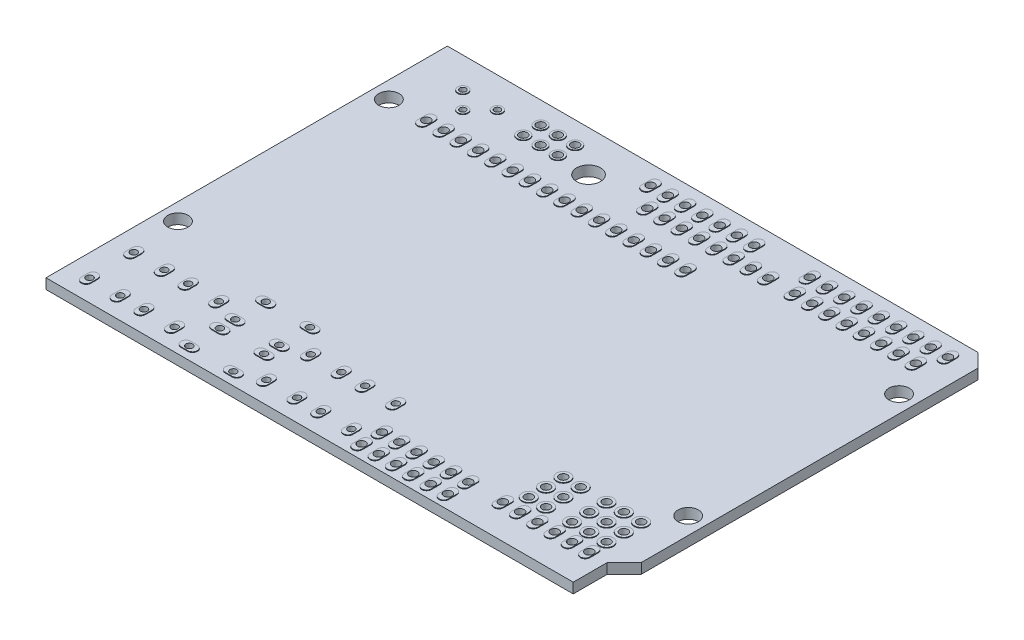
from build123d import *

# Parameters (mm, degrees)
SKETCH1_R                = 0.6
SKETCH1_R_2              = 1.5
SKETCH1_R_3              = 0.5
SKETCH1_R_4              = 0.45
SKETCH1_R_5              = 1.75
PCB_DEPTH                = 1.5
SKETCH2_R                = 0.9
SKETCH2_R_2              = 0.6
SKETCH2_R_3              = 1
SKETCH2_R_4              = 0.75
SKETCH2_R_5              = 0.45
SKETCH2_R_6              = 0.5
BOSS_EXTRUDE1_DEPTH      = 0.1
BOSS_EXTRUDE1_DEPTH_BACK = 1.61


with BuildPart() as part:
    # Sketch1 → PCB (new body)
    with BuildSketch(Plane(origin=(0, 0, 0), x_dir=(1, 0, 0), z_dir=(0, 1, 0))):
        Polygon((0, 0), (77.5, 0), (77.5, 5), (80, 7.5), (80, 57), (78, 59), (0, 59), align=None)
        with Locations((17, 55.7)):
            Circle(SKETCH1_R, mode=Mode.SUBTRACT)
        with Locations((19.54, 55.7)):
            Circle(SKETCH1_R, mode=Mode.SUBTRACT)
        with Locations((22.08, 55.7)):
            Circle(SKETCH1_R, mode=Mode.SUBTRACT)
        with Locations((19.54, 53.16)):
            Circle(SKETCH1_R, mode=Mode.SUBTRACT)
        with Locations((22.08, 53.16)):
            Circle(SKETCH1_R, mode=Mode.SUBTRACT)
        with Locations((17, 53.16)):
            Circle(SKETCH1_R, mode=Mode.SUBTRACT)
        with Locations((32.76224884, 56.1)):
            Circle(SKETCH1_R, mode=Mode.SUBTRACT)
        with Locations((35.433136068, 52.95)):
            Circle(SKETCH1_R, mode=Mode.SUBTRACT)
        with Locations((35.30224884, 56.1)):
            Circle(SKETCH1_R, mode=Mode.SUBTRACT)
        with Locations((37.84224884, 56.1)):
            Circle(SKETCH1_R, mode=Mode.SUBTRACT)
        with Locations((40.38224884, 56.1)):
            Circle(SKETCH1_R, mode=Mode.SUBTRACT)
        with Locations((42.92224884, 56.1)):
            Circle(SKETCH1_R, mode=Mode.SUBTRACT)
        with Locations((45.46224884, 56.1)):
            Circle(SKETCH1_R, mode=Mode.SUBTRACT)
        with Locations((48.00224884, 56.1)):
            Circle(SKETCH1_R, mode=Mode.SUBTRACT)
        with Locations((37.973136068, 52.95)):
            Circle(SKETCH1_R, mode=Mode.SUBTRACT)
        with Locations((40.513136068, 52.95)):
            Circle(SKETCH1_R, mode=Mode.SUBTRACT)
        with Locations((43.053136068, 52.95)):
            Circle(SKETCH1_R, mode=Mode.SUBTRACT)
        with Locations((45.593136068, 52.95)):
            Circle(SKETCH1_R, mode=Mode.SUBTRACT)
        with Locations((48.133136068, 52.95)):
            Circle(SKETCH1_R, mode=Mode.SUBTRACT)
        with Locations((50.673136068, 52.95)):
            Circle(SKETCH1_R, mode=Mode.SUBTRACT)
        with Locations((53.213136068, 52.95)):
            Circle(SKETCH1_R, mode=Mode.SUBTRACT)
        with Locations((56.16224884, 56.1)):
            Circle(SKETCH1_R, mode=Mode.SUBTRACT)
        with Locations((57.130136068, 52.95)):
            Circle(SKETCH1_R, mode=Mode.SUBTRACT)
        with Locations((59.670136068, 52.95)):
            Circle(SKETCH1_R, mode=Mode.SUBTRACT)
        with Locations((62.210136068, 52.95)):
            Circle(SKETCH1_R, mode=Mode.SUBTRACT)
        with Locations((64.750136068, 52.95)):
            Circle(SKETCH1_R, mode=Mode.SUBTRACT)
        with Locations((67.290136068, 52.95)):
            Circle(SKETCH1_R, mode=Mode.SUBTRACT)
        with Locations((69.830136068, 52.95)):
            Circle(SKETCH1_R, mode=Mode.SUBTRACT)
        with Locations((72.370136068, 52.95)):
            Circle(SKETCH1_R, mode=Mode.SUBTRACT)
        with Locations((74.910136068, 52.95)):
            Circle(SKETCH1_R, mode=Mode.SUBTRACT)
        with Locations((58.70224884, 56.1)):
            Circle(SKETCH1_R, mode=Mode.SUBTRACT)
        with Locations((61.24224884, 56.1)):
            Circle(SKETCH1_R, mode=Mode.SUBTRACT)
        with Locations((63.78224884, 56.1)):
            Circle(SKETCH1_R, mode=Mode.SUBTRACT)
        with Locations((66.32224884, 56.1)):
            Circle(SKETCH1_R, mode=Mode.SUBTRACT)
        with Locations((68.86224884, 56.1)):
            Circle(SKETCH1_R, mode=Mode.SUBTRACT)
        with Locations((71.40224884, 56.1)):
            Circle(SKETCH1_R, mode=Mode.SUBTRACT)
        with Locations((73.94224884, 56.1)):
            Circle(SKETCH1_R, mode=Mode.SUBTRACT)
        with Locations((76.48224884, 56.1)):
            Circle(SKETCH1_R, mode=Mode.SUBTRACT)
        with Locations((8, 47.9)):
            Circle(SKETCH1_R, mode=Mode.SUBTRACT)
        with Locations((10.54, 47.9)):
            Circle(SKETCH1_R, mode=Mode.SUBTRACT)
        with Locations((13.08, 47.9)):
            Circle(SKETCH1_R, mode=Mode.SUBTRACT)
        with Locations((15.62, 47.9)):
            Circle(SKETCH1_R, mode=Mode.SUBTRACT)
        with Locations((18.16, 47.9)):
            Circle(SKETCH1_R, mode=Mode.SUBTRACT)
        with Locations((20.7, 47.9)):
            Circle(SKETCH1_R, mode=Mode.SUBTRACT)
        with Locations((23.24, 47.9)):
            Circle(SKETCH1_R, mode=Mode.SUBTRACT)
        with Locations((25.78, 47.9)):
            Circle(SKETCH1_R, mode=Mode.SUBTRACT)
        with Locations((28.32, 47.9)):
            Circle(SKETCH1_R, mode=Mode.SUBTRACT)
        with Locations((30.86, 47.9)):
            Circle(SKETCH1_R, mode=Mode.SUBTRACT)
        with Locations((33.4, 47.9)):
            Circle(SKETCH1_R, mode=Mode.SUBTRACT)
        with Locations((35.94, 47.9)):
            Circle(SKETCH1_R, mode=Mode.SUBTRACT)
        with Locations((38.48, 47.9)):
            Circle(SKETCH1_R, mode=Mode.SUBTRACT)
        with Locations((41.02, 47.9)):
            Circle(SKETCH1_R, mode=Mode.SUBTRACT)
        with Locations((43.56, 47.9)):
            Circle(SKETCH1_R, mode=Mode.SUBTRACT)
        with Locations((46.1, 47.9)):
            Circle(SKETCH1_R, mode=Mode.SUBTRACT)
        with Locations((74.910136068, 4.95)):
            Circle(SKETCH1_R, mode=Mode.SUBTRACT)
        with Locations((72.370136068, 4.95)):
            Circle(SKETCH1_R, mode=Mode.SUBTRACT)
        with Locations((69.830136068, 4.95)):
            Circle(SKETCH1_R, mode=Mode.SUBTRACT)
        with Locations((67.290136068, 4.95)):
            Circle(SKETCH1_R, mode=Mode.SUBTRACT)
        with Locations((64.750136068, 4.95)):
            Circle(SKETCH1_R, mode=Mode.SUBTRACT)
        with Locations((62.210136068, 4.95)):
            Circle(SKETCH1_R, mode=Mode.SUBTRACT)
        with Locations((57.130136068, 4.95)):
            Circle(SKETCH1_R, mode=Mode.SUBTRACT)
        with Locations((54.590136068, 4.95)):
            Circle(SKETCH1_R, mode=Mode.SUBTRACT)
        with Locations((52.050136068, 4.95)):
            Circle(SKETCH1_R, mode=Mode.SUBTRACT)
        with Locations((49.510136068, 4.95)):
            Circle(SKETCH1_R, mode=Mode.SUBTRACT)
        with Locations((46.970136068, 4.95)):
            Circle(SKETCH1_R, mode=Mode.SUBTRACT)
        with Locations((44.430136068, 4.95)):
            Circle(SKETCH1_R, mode=Mode.SUBTRACT)
        with Locations((57.130136068, 1.95)):
            Circle(SKETCH1_R, mode=Mode.SUBTRACT)
        with Locations((54.590136068, 1.95)):
            Circle(SKETCH1_R, mode=Mode.SUBTRACT)
        with Locations((52.050136068, 1.95)):
            Circle(SKETCH1_R, mode=Mode.SUBTRACT)
        with Locations((49.510136068, 1.95)):
            Circle(SKETCH1_R, mode=Mode.SUBTRACT)
        with Locations((46.970136068, 1.95)):
            Circle(SKETCH1_R, mode=Mode.SUBTRACT)
        with Locations((44.430136068, 1.95)):
            Circle(SKETCH1_R, mode=Mode.SUBTRACT)
        with Locations((63.480136068, 7.49)):
            Circle(SKETCH1_R, mode=Mode.SUBTRACT)
        with Locations((74.910136068, 7.49)):
            Circle(SKETCH1_R, mode=Mode.SUBTRACT)
        with Locations((72.370136068, 7.49)):
            Circle(SKETCH1_R, mode=Mode.SUBTRACT)
        with Locations((69.830136068, 7.49)):
            Circle(SKETCH1_R, mode=Mode.SUBTRACT)
        with Locations((74.910136068, 10.03)):
            Circle(SKETCH1_R, mode=Mode.SUBTRACT)
        with Locations((72.370136068, 10.03)):
            Circle(SKETCH1_R, mode=Mode.SUBTRACT)
        with Locations((69.830136068, 10.03)):
            Circle(SKETCH1_R, mode=Mode.SUBTRACT)
        with Locations((74.910136068, 12.57)):
            Circle(SKETCH1_R, mode=Mode.SUBTRACT)
        with Locations((72.370136068, 12.57)):
            Circle(SKETCH1_R, mode=Mode.SUBTRACT)
        with Locations((69.830136068, 12.57)):
            Circle(SKETCH1_R, mode=Mode.SUBTRACT)
        with Locations((66.020136068, 7.49)):
            Circle(SKETCH1_R, mode=Mode.SUBTRACT)
        with Locations((66.020136068, 10.03)):
            Circle(SKETCH1_R, mode=Mode.SUBTRACT)
        with Locations((66.020136068, 12.57)):
            Circle(SKETCH1_R, mode=Mode.SUBTRACT)
        with Locations((63.480136068, 10.03)):
            Circle(SKETCH1_R, mode=Mode.SUBTRACT)
        with Locations((63.480136068, 12.57)):
            Circle(SKETCH1_R, mode=Mode.SUBTRACT)
        with Locations((2.5, 47.9)):
            Circle(SKETCH1_R_2, mode=Mode.SUBTRACT)
        with Locations((77.5, 47.9)):
            Circle(SKETCH1_R_2, mode=Mode.SUBTRACT)
        with Locations((77.5, 16.9)):
            Circle(SKETCH1_R_2, mode=Mode.SUBTRACT)
        with Locations((2.5, 16.9)):
            Circle(SKETCH1_R_2, mode=Mode.SUBTRACT)
        with Locations((3.3, 9.6)):
            Circle(SKETCH1_R_3, mode=Mode.SUBTRACT)
        with Locations((7.8, 9.6)):
            Circle(SKETCH1_R_3, mode=Mode.SUBTRACT)
        with Locations((7.8, 3.1)):
            Circle(SKETCH1_R_3, mode=Mode.SUBTRACT)
        with Locations((3.3, 3.1)):
            Circle(SKETCH1_R_3, mode=Mode.SUBTRACT)
        with Locations((11.3, 9.6)):
            Circle(SKETCH1_R_3, mode=Mode.SUBTRACT)
        with Locations((15.8, 9.6)):
            Circle(SKETCH1_R_3, mode=Mode.SUBTRACT)
        with Locations((15.8, 3.1)):
            Circle(SKETCH1_R_3, mode=Mode.SUBTRACT)
        with Locations((11.3, 3.1)):
            Circle(SKETCH1_R_3, mode=Mode.SUBTRACT)
        with Locations((29.3, 9.6)):
            Circle(SKETCH1_R_3, mode=Mode.SUBTRACT)
        with Locations((33.8, 9.6)):
            Circle(SKETCH1_R_3, mode=Mode.SUBTRACT)
        with Locations((33.8, 3.1)):
            Circle(SKETCH1_R_3, mode=Mode.SUBTRACT)
        with Locations((29.3, 3.1)):
            Circle(SKETCH1_R_3, mode=Mode.SUBTRACT)
        with Locations((41.8, 3.1)):
            Circle(SKETCH1_R_3, mode=Mode.SUBTRACT)
        with Locations((41.8, 9.6)):
            Circle(SKETCH1_R_3, mode=Mode.SUBTRACT)
        with Locations((37.3, 9.6)):
            Circle(SKETCH1_R_3, mode=Mode.SUBTRACT)
        with Locations((37.3, 3.1)):
            Circle(SKETCH1_R_3, mode=Mode.SUBTRACT)
        with Locations((19.3, 6.25)):
            Circle(SKETCH1_R_3, mode=Mode.SUBTRACT)
        with Locations((25.8, 6.25)):
            Circle(SKETCH1_R_3, mode=Mode.SUBTRACT)
        with Locations((25.8, 1.75)):
            Circle(SKETCH1_R_3, mode=Mode.SUBTRACT)
        with Locations((19.3, 1.75)):
            Circle(SKETCH1_R_3, mode=Mode.SUBTRACT)
        with Locations((19.3, 13)):
            Circle(SKETCH1_R_3, mode=Mode.SUBTRACT)
        with Locations((19.3, 8.5)):
            Circle(SKETCH1_R_3, mode=Mode.SUBTRACT)
        with Locations((25.8, 13)):
            Circle(SKETCH1_R_3, mode=Mode.SUBTRACT)
        with Locations((25.8, 8.5)):
            Circle(SKETCH1_R_3, mode=Mode.SUBTRACT)
        with Locations((6.8, 54.47)):
            Circle(SKETCH1_R_4, mode=Mode.SUBTRACT)
        with Locations((11.88, 54.47)):
            Circle(SKETCH1_R_4, mode=Mode.SUBTRACT)
        with Locations((9.34, 51.93)):
            Circle(SKETCH1_R_4, mode=Mode.SUBTRACT)
        with Locations((26.75, 53)):
            Circle(SKETCH1_R_5, mode=Mode.SUBTRACT)
    extrude(amount=-PCB_DEPTH)

    # Sketch2 → Boss-Extrude1 (add, two sides)
    with BuildSketch(Plane(origin=(0, 0, 0), x_dir=(1, 0, 0), z_dir=(0, 1, 0))) as boss_extrude1_sk:
        with Locations((17, 55.7)):
            Circle(SKETCH2_R)
        with Locations((17, 55.7)):
            Circle(SKETCH2_R_2, mode=Mode.SUBTRACT)
        with Locations((17, 53.16)):
            Circle(SKETCH2_R)
        with Locations((17, 53.16)):
            Circle(SKETCH2_R_2, mode=Mode.SUBTRACT)
        with Locations((19.54, 53.16)):
            Circle(SKETCH2_R)
        with Locations((19.54, 53.16)):
            Circle(SKETCH2_R_2, mode=Mode.SUBTRACT)
        with Locations((19.54, 55.7)):
            Circle(SKETCH2_R)
        with Locations((19.54, 55.7)):
            Circle(SKETCH2_R_2, mode=Mode.SUBTRACT)
        with Locations((22.08, 55.7)):
            Circle(SKETCH2_R)
        with Locations((22.08, 55.7)):
            Circle(SKETCH2_R_2, mode=Mode.SUBTRACT)
        with Locations((22.08, 53.16)):
            Circle(SKETCH2_R)
        with Locations((22.08, 53.16)):
            Circle(SKETCH2_R_2, mode=Mode.SUBTRACT)
        with Locations((63.480136068, 7.49)):
            Circle(SKETCH2_R_3)
        with Locations((63.480136068, 7.49)):
            Circle(SKETCH2_R_2, mode=Mode.SUBTRACT)
        with Locations((69.830136068, 7.49)):
            Circle(SKETCH2_R_3)
        with Locations((69.830136068, 7.49)):
            Circle(SKETCH2_R_2, mode=Mode.SUBTRACT)
        with Locations((63.480136068, 12.57)):
            Circle(SKETCH2_R_3)
        with Locations((63.480136068, 12.57)):
            Circle(SKETCH2_R_2, mode=Mode.SUBTRACT)
        with Locations((63.480136068, 10.03)):
            Circle(SKETCH2_R_3)
        with Locations((63.480136068, 10.03)):
            Circle(SKETCH2_R_2, mode=Mode.SUBTRACT)
        with Locations((66.020136068, 7.49)):
            Circle(SKETCH2_R_3)
        with Locations((66.020136068, 7.49)):
            Circle(SKETCH2_R_2, mode=Mode.SUBTRACT)
        with Locations((66.020136068, 10.03)):
            Circle(SKETCH2_R_3)
        with Locations((66.020136068, 10.03)):
            Circle(SKETCH2_R_2, mode=Mode.SUBTRACT)
        with Locations((66.020136068, 12.57)):
            Circle(SKETCH2_R_3)
        with Locations((66.020136068, 12.57)):
            Circle(SKETCH2_R_2, mode=Mode.SUBTRACT)
        with Locations((69.830136068, 12.57)):
            Circle(SKETCH2_R_3)
        with Locations((69.830136068, 12.57)):
            Circle(SKETCH2_R_2, mode=Mode.SUBTRACT)
        with Locations((69.830136068, 10.03)):
            Circle(SKETCH2_R_3)
        with Locations((69.830136068, 10.03)):
            Circle(SKETCH2_R_2, mode=Mode.SUBTRACT)
        with Locations((72.370136068, 10.03)):
            Circle(SKETCH2_R_3)
        with Locations((72.370136068, 10.03)):
            Circle(SKETCH2_R_2, mode=Mode.SUBTRACT)
        with Locations((72.370136068, 12.57)):
            Circle(SKETCH2_R_3)
        with Locations((72.370136068, 12.57)):
            Circle(SKETCH2_R_2, mode=Mode.SUBTRACT)
        with Locations((74.910136068, 12.57)):
            Circle(SKETCH2_R_3)
        with Locations((74.910136068, 12.57)):
            Circle(SKETCH2_R_2, mode=Mode.SUBTRACT)
        with Locations((74.910136068, 10.03)):
            Circle(SKETCH2_R_3)
        with Locations((74.910136068, 10.03)):
            Circle(SKETCH2_R_2, mode=Mode.SUBTRACT)
        with Locations((74.910136068, 7.49)):
            Circle(SKETCH2_R_3)
        with Locations((74.910136068, 7.49)):
            Circle(SKETCH2_R_2, mode=Mode.SUBTRACT)
        with Locations((72.370136068, 7.49)):
            Circle(SKETCH2_R_3)
        with Locations((72.370136068, 7.49)):
            Circle(SKETCH2_R_2, mode=Mode.SUBTRACT)
        with Locations((6.8, 54.47)):
            Circle(SKETCH2_R_4)
        with Locations((6.8, 54.47)):
            Circle(SKETCH2_R_5, mode=Mode.SUBTRACT)
        with Locations((9.34, 51.93)):
            Circle(SKETCH2_R_4)
        with Locations((9.34, 51.93)):
            Circle(SKETCH2_R_5, mode=Mode.SUBTRACT)
        with Locations((11.88, 54.47)):
            Circle(SKETCH2_R_4)
        with Locations((11.88, 54.47)):
            Circle(SKETCH2_R_5, mode=Mode.SUBTRACT)
        with BuildLine():
            Line((33.46224884, 56.7), (33.46224884, 55.5))
            ThreePointArc((33.46224884, 55.5), (32.76224884, 54.8), (32.06224884, 55.5))
            Line((32.06224884, 55.5), (32.06224884, 56.7))
            ThreePointArc((32.06224884, 56.7), (32.76224884, 57.4), (33.46224884, 56.7))
        make_face()
        with Locations((32.76224884, 56.1)):
            Circle(SKETCH2_R_2, mode=Mode.SUBTRACT)
        with BuildLine():
            Line((36.00224884, 56.7), (36.00224884, 55.5))
            ThreePointArc((36.00224884, 55.5), (35.30224884, 54.8), (34.60224884, 55.5))
            Line((34.60224884, 55.5), (34.60224884, 56.7))
            ThreePointArc((34.60224884, 56.7), (35.30224884, 57.4), (36.00224884, 56.7))
        make_face()
        with Locations((35.30224884, 56.1)):
            Circle(SKETCH2_R_2, mode=Mode.SUBTRACT)
        with BuildLine():
            Line((38.54224884, 56.7), (38.54224884, 55.5))
            ThreePointArc((38.54224884, 55.5), (37.84224884, 54.8), (37.14224884, 55.5))
            Line((37.14224884, 55.5), (37.14224884, 56.7))
            ThreePointArc((37.14224884, 56.7), (37.84224884, 57.4), (38.54224884, 56.7))
        make_face()
        with Locations((37.84224884, 56.1)):
            Circle(SKETCH2_R_2, mode=Mode.SUBTRACT)
        with BuildLine():
            Line((41.08224884, 56.7), (41.08224884, 55.5))
            ThreePointArc((41.08224884, 55.5), (40.38224884, 54.8), (39.68224884, 55.5))
            Line((39.68224884, 55.5), (39.68224884, 56.7))
            ThreePointArc((39.68224884, 56.7), (40.38224884, 57.4), (41.08224884, 56.7))
        make_face()
        with Locations((40.38224884, 56.1)):
            Circle(SKETCH2_R_2, mode=Mode.SUBTRACT)
        with BuildLine():
            Line((43.62224884, 56.7), (43.62224884, 55.5))
            ThreePointArc((43.62224884, 55.5), (42.92224884, 54.8), (42.22224884, 55.5))
            Line((42.22224884, 55.5), (42.22224884, 56.7))
            ThreePointArc((42.22224884, 56.7), (42.92224884, 57.4), (43.62224884, 56.7))
        make_face()
        with Locations((42.92224884, 56.1)):
            Circle(SKETCH2_R_2, mode=Mode.SUBTRACT)
        with BuildLine():
            Line((46.16224884, 56.7), (46.16224884, 55.5))
            ThreePointArc((46.16224884, 55.5), (45.46224884, 54.8), (44.76224884, 55.5))
            Line((44.76224884, 55.5), (44.76224884, 56.7))
            ThreePointArc((44.76224884, 56.7), (45.46224884, 57.4), (46.16224884, 56.7))
        make_face()
        with Locations((45.46224884, 56.1)):
            Circle(SKETCH2_R_2, mode=Mode.SUBTRACT)
        with BuildLine():
            Line((48.70224884, 56.7), (48.70224884, 55.5))
            ThreePointArc((48.70224884, 55.5), (48.00224884, 54.8), (47.30224884, 55.5))
            Line((47.30224884, 55.5), (47.30224884, 56.7))
            ThreePointArc((47.30224884, 56.7), (48.00224884, 57.4), (48.70224884, 56.7))
        make_face()
        with Locations((48.00224884, 56.1)):
            Circle(SKETCH2_R_2, mode=Mode.SUBTRACT)
        with BuildLine():
            Line((36.133136068, 53.55), (36.133136068, 52.35))
            ThreePointArc((36.133136068, 52.35), (35.433136068, 51.65), (34.733136068, 52.35))
            Line((34.733136068, 52.35), (34.733136068, 53.55))
            ThreePointArc((34.733136068, 53.55), (35.433136068, 54.25), (36.133136068, 53.55))
        make_face()
        with Locations((35.433136068, 52.95)):
            Circle(SKETCH2_R_2, mode=Mode.SUBTRACT)
        with BuildLine():
            Line((56.86224884, 56.7), (56.86224884, 55.5))
            ThreePointArc((56.86224884, 55.5), (56.16224884, 54.8), (55.46224884, 55.5))
            Line((55.46224884, 55.5), (55.46224884, 56.7))
            ThreePointArc((55.46224884, 56.7), (56.16224884, 57.4), (56.86224884, 56.7))
        make_face()
        with Locations((56.16224884, 56.1)):
            Circle(SKETCH2_R_2, mode=Mode.SUBTRACT)
        with BuildLine():
            Line((57.830136068, 53.55), (57.830136068, 52.35))
            ThreePointArc((57.830136068, 52.35), (57.130136068, 51.65), (56.430136068, 52.35))
            Line((56.430136068, 52.35), (56.430136068, 53.55))
            ThreePointArc((56.430136068, 53.55), (57.130136068, 54.25), (57.830136068, 53.55))
        make_face()
        with Locations((57.130136068, 52.95)):
            Circle(SKETCH2_R_2, mode=Mode.SUBTRACT)
        with BuildLine():
            Line((8.7, 48.5), (8.7, 47.3))
            ThreePointArc((8.7, 47.3), (8, 46.6), (7.3, 47.3))
            Line((7.3, 47.3), (7.3, 48.5))
            ThreePointArc((7.3, 48.5), (8, 49.2), (8.7, 48.5))
        make_face()
        with Locations((8, 47.9)):
            Circle(SKETCH2_R_2, mode=Mode.SUBTRACT)
        with BuildLine():
            Line((4, 10.1), (4, 9.1))
            ThreePointArc((4, 9.1), (3.3, 8.4), (2.6, 9.1))
            Line((2.6, 9.1), (2.6, 10.1))
            ThreePointArc((2.6, 10.1), (3.3, 10.8), (4, 10.1))
        make_face()
        with Locations((3.3, 9.6)):
            Circle(SKETCH2_R_6, mode=Mode.SUBTRACT)
        with BuildLine():
            Line((18.8, 2.45), (19.8, 2.45))
            ThreePointArc((19.8, 2.45), (20.5, 1.75), (19.8, 1.05))
            Line((19.8, 1.05), (18.8, 1.05))
            ThreePointArc((18.8, 1.05), (18.1, 1.75), (18.8, 2.45))
        make_face()
        with Locations((19.3, 1.75)):
            Circle(SKETCH2_R_6, mode=Mode.SUBTRACT)
        with BuildLine():
            Line((30, 10.1), (30, 9.1))
            ThreePointArc((30, 9.1), (29.3, 8.4), (28.6, 9.1))
            Line((28.6, 9.1), (28.6, 10.1))
            ThreePointArc((28.6, 10.1), (29.3, 10.8), (30, 10.1))
        make_face()
        with Locations((29.3, 9.6)):
            Circle(SKETCH2_R_6, mode=Mode.SUBTRACT)
        with BuildLine():
            Line((45.130136068, 5.55), (45.130136068, 4.35))
            ThreePointArc((45.130136068, 4.35), (44.430136068, 3.65), (43.730136068, 4.35))
            Line((43.730136068, 4.35), (43.730136068, 5.55))
            ThreePointArc((43.730136068, 5.55), (44.430136068, 6.25), (45.130136068, 5.55))
        make_face()
        with Locations((44.430136068, 4.95)):
            Circle(SKETCH2_R_2, mode=Mode.SUBTRACT)
        with BuildLine():
            Line((61.510136068, 4.35), (61.510136068, 5.55))
            ThreePointArc((61.510136068, 5.55), (62.210136068, 6.25), (62.910136068, 5.55))
            Line((62.910136068, 5.55), (62.910136068, 4.35))
            ThreePointArc((62.910136068, 4.35), (62.210136068, 3.65), (61.510136068, 4.35))
        make_face()
        with Locations((62.210136068, 4.95)):
            Circle(SKETCH2_R_2, mode=Mode.SUBTRACT)
        with BuildLine():
            Line((8.5, 10.1), (8.5, 9.1))
            ThreePointArc((8.5, 9.1), (7.8, 8.4), (7.1, 9.1))
            Line((7.1, 9.1), (7.1, 10.1))
            ThreePointArc((7.1, 10.1), (7.8, 10.8), (8.5, 10.1))
        make_face()
        with Locations((7.8, 9.6)):
            Circle(SKETCH2_R_6, mode=Mode.SUBTRACT)
        with BuildLine():
            Line((8.5, 3.6), (8.5, 2.6))
            ThreePointArc((8.5, 2.6), (7.8, 1.9), (7.1, 2.6))
            Line((7.1, 2.6), (7.1, 3.6))
            ThreePointArc((7.1, 3.6), (7.8, 4.3), (8.5, 3.6))
        make_face()
        with Locations((7.8, 3.1)):
            Circle(SKETCH2_R_6, mode=Mode.SUBTRACT)
        with BuildLine():
            Line((38.673136068, 53.55), (38.673136068, 52.35))
            ThreePointArc((38.673136068, 52.35), (37.973136068, 51.65), (37.273136068, 52.35))
            Line((37.273136068, 52.35), (37.273136068, 53.55))
            ThreePointArc((37.273136068, 53.55), (37.973136068, 54.25), (38.673136068, 53.55))
        make_face()
        with Locations((37.973136068, 52.95)):
            Circle(SKETCH2_R_2, mode=Mode.SUBTRACT)
        with BuildLine():
            Line((60.370136068, 53.55), (60.370136068, 52.35))
            ThreePointArc((60.370136068, 52.35), (59.670136068, 51.65), (58.970136068, 52.35))
            Line((58.970136068, 52.35), (58.970136068, 53.55))
            ThreePointArc((58.970136068, 53.55), (59.670136068, 54.25), (60.370136068, 53.55))
        make_face()
        with Locations((59.670136068, 52.95)):
            Circle(SKETCH2_R_2, mode=Mode.SUBTRACT)
        with BuildLine():
            Line((41.213136068, 53.55), (41.213136068, 52.35))
            ThreePointArc((41.213136068, 52.35), (40.513136068, 51.65), (39.813136068, 52.35))
            Line((39.813136068, 52.35), (39.813136068, 53.55))
            ThreePointArc((39.813136068, 53.55), (40.513136068, 54.25), (41.213136068, 53.55))
        make_face()
        with Locations((40.513136068, 52.95)):
            Circle(SKETCH2_R_2, mode=Mode.SUBTRACT)
        with BuildLine():
            Line((62.910136068, 53.55), (62.910136068, 52.35))
            ThreePointArc((62.910136068, 52.35), (62.210136068, 51.65), (61.510136068, 52.35))
            Line((61.510136068, 52.35), (61.510136068, 53.55))
            ThreePointArc((61.510136068, 53.55), (62.210136068, 54.25), (62.910136068, 53.55))
        make_face()
        with Locations((62.210136068, 52.95)):
            Circle(SKETCH2_R_2, mode=Mode.SUBTRACT)
        with BuildLine():
            Line((43.753136068, 53.55), (43.753136068, 52.35))
            ThreePointArc((43.753136068, 52.35), (43.053136068, 51.65), (42.353136068, 52.35))
            Line((42.353136068, 52.35), (42.353136068, 53.55))
            ThreePointArc((42.353136068, 53.55), (43.053136068, 54.25), (43.753136068, 53.55))
        make_face()
        with Locations((43.053136068, 52.95)):
            Circle(SKETCH2_R_2, mode=Mode.SUBTRACT)
        with BuildLine():
            Line((65.450136068, 53.55), (65.450136068, 52.35))
            ThreePointArc((65.450136068, 52.35), (64.750136068, 51.65), (64.050136068, 52.35))
            Line((64.050136068, 52.35), (64.050136068, 53.55))
            ThreePointArc((64.050136068, 53.55), (64.750136068, 54.25), (65.450136068, 53.55))
        make_face()
        with Locations((64.750136068, 52.95)):
            Circle(SKETCH2_R_2, mode=Mode.SUBTRACT)
        with BuildLine():
            Line((46.293136068, 53.55), (46.293136068, 52.35))
            ThreePointArc((46.293136068, 52.35), (45.593136068, 51.65), (44.893136068, 52.35))
            Line((44.893136068, 52.35), (44.893136068, 53.55))
            ThreePointArc((44.893136068, 53.55), (45.593136068, 54.25), (46.293136068, 53.55))
        make_face()
        with Locations((45.593136068, 52.95)):
            Circle(SKETCH2_R_2, mode=Mode.SUBTRACT)
        with BuildLine():
            Line((67.990136068, 53.55), (67.990136068, 52.35))
            ThreePointArc((67.990136068, 52.35), (67.290136068, 51.65), (66.590136068, 52.35))
            Line((66.590136068, 52.35), (66.590136068, 53.55))
            ThreePointArc((66.590136068, 53.55), (67.290136068, 54.25), (67.990136068, 53.55))
        make_face()
        with Locations((67.290136068, 52.95)):
            Circle(SKETCH2_R_2, mode=Mode.SUBTRACT)
        with BuildLine():
            Line((48.833136068, 53.55), (48.833136068, 52.35))
            ThreePointArc((48.833136068, 52.35), (48.133136068, 51.65), (47.433136068, 52.35))
            Line((47.433136068, 52.35), (47.433136068, 53.55))
            ThreePointArc((47.433136068, 53.55), (48.133136068, 54.25), (48.833136068, 53.55))
        make_face()
        with Locations((48.133136068, 52.95)):
            Circle(SKETCH2_R_2, mode=Mode.SUBTRACT)
        with BuildLine():
            Line((70.530136068, 53.55), (70.530136068, 52.35))
            ThreePointArc((70.530136068, 52.35), (69.830136068, 51.65), (69.130136068, 52.35))
            Line((69.130136068, 52.35), (69.130136068, 53.55))
            ThreePointArc((69.130136068, 53.55), (69.830136068, 54.25), (70.530136068, 53.55))
        make_face()
        with Locations((69.830136068, 52.95)):
            Circle(SKETCH2_R_2, mode=Mode.SUBTRACT)
        with BuildLine():
            Line((51.373136068, 53.55), (51.373136068, 52.35))
            ThreePointArc((51.373136068, 52.35), (50.673136068, 51.65), (49.973136068, 52.35))
            Line((49.973136068, 52.35), (49.973136068, 53.55))
            ThreePointArc((49.973136068, 53.55), (50.673136068, 54.25), (51.373136068, 53.55))
        make_face()
        with Locations((50.673136068, 52.95)):
            Circle(SKETCH2_R_2, mode=Mode.SUBTRACT)
        with BuildLine():
            Line((73.070136068, 53.55), (73.070136068, 52.35))
            ThreePointArc((73.070136068, 52.35), (72.370136068, 51.65), (71.670136068, 52.35))
            Line((71.670136068, 52.35), (71.670136068, 53.55))
            ThreePointArc((71.670136068, 53.55), (72.370136068, 54.25), (73.070136068, 53.55))
        make_face()
        with Locations((72.370136068, 52.95)):
            Circle(SKETCH2_R_2, mode=Mode.SUBTRACT)
        with BuildLine():
            Line((53.913136068, 53.55), (53.913136068, 52.35))
            ThreePointArc((53.913136068, 52.35), (53.213136068, 51.65), (52.513136068, 52.35))
            Line((52.513136068, 52.35), (52.513136068, 53.55))
            ThreePointArc((52.513136068, 53.55), (53.213136068, 54.25), (53.913136068, 53.55))
        make_face()
        with Locations((53.213136068, 52.95)):
            Circle(SKETCH2_R_2, mode=Mode.SUBTRACT)
        with BuildLine():
            Line((75.610136068, 53.55), (75.610136068, 52.35))
            ThreePointArc((75.610136068, 52.35), (74.910136068, 51.65), (74.210136068, 52.35))
            Line((74.210136068, 52.35), (74.210136068, 53.55))
            ThreePointArc((74.210136068, 53.55), (74.910136068, 54.25), (75.610136068, 53.55))
        make_face()
        with Locations((74.910136068, 52.95)):
            Circle(SKETCH2_R_2, mode=Mode.SUBTRACT)
        with BuildLine():
            Line((59.40224884, 56.7), (59.40224884, 55.5))
            ThreePointArc((59.40224884, 55.5), (58.70224884, 54.8), (58.00224884, 55.5))
            Line((58.00224884, 55.5), (58.00224884, 56.7))
            ThreePointArc((58.00224884, 56.7), (58.70224884, 57.4), (59.40224884, 56.7))
        make_face()
        with Locations((58.70224884, 56.1)):
            Circle(SKETCH2_R_2, mode=Mode.SUBTRACT)
        with BuildLine():
            Line((61.94224884, 56.7), (61.94224884, 55.5))
            ThreePointArc((61.94224884, 55.5), (61.24224884, 54.8), (60.54224884, 55.5))
            Line((60.54224884, 55.5), (60.54224884, 56.7))
            ThreePointArc((60.54224884, 56.7), (61.24224884, 57.4), (61.94224884, 56.7))
        make_face()
        with Locations((61.24224884, 56.1)):
            Circle(SKETCH2_R_2, mode=Mode.SUBTRACT)
        with BuildLine():
            Line((64.48224884, 56.7), (64.48224884, 55.5))
            ThreePointArc((64.48224884, 55.5), (63.78224884, 54.8), (63.08224884, 55.5))
            Line((63.08224884, 55.5), (63.08224884, 56.7))
            ThreePointArc((63.08224884, 56.7), (63.78224884, 57.4), (64.48224884, 56.7))
        make_face()
        with Locations((63.78224884, 56.1)):
            Circle(SKETCH2_R_2, mode=Mode.SUBTRACT)
        with BuildLine():
            Line((67.02224884, 56.7), (67.02224884, 55.5))
            ThreePointArc((67.02224884, 55.5), (66.32224884, 54.8), (65.62224884, 55.5))
            Line((65.62224884, 55.5), (65.62224884, 56.7))
            ThreePointArc((65.62224884, 56.7), (66.32224884, 57.4), (67.02224884, 56.7))
        make_face()
        with Locations((66.32224884, 56.1)):
            Circle(SKETCH2_R_2, mode=Mode.SUBTRACT)
        with BuildLine():
            Line((69.56224884, 56.7), (69.56224884, 55.5))
            ThreePointArc((69.56224884, 55.5), (68.86224884, 54.8), (68.16224884, 55.5))
            Line((68.16224884, 55.5), (68.16224884, 56.7))
            ThreePointArc((68.16224884, 56.7), (68.86224884, 57.4), (69.56224884, 56.7))
        make_face()
        with Locations((68.86224884, 56.1)):
            Circle(SKETCH2_R_2, mode=Mode.SUBTRACT)
        with BuildLine():
            Line((72.10224884, 56.7), (72.10224884, 55.5))
            ThreePointArc((72.10224884, 55.5), (71.40224884, 54.8), (70.70224884, 55.5))
            Line((70.70224884, 55.5), (70.70224884, 56.7))
            ThreePointArc((70.70224884, 56.7), (71.40224884, 57.4), (72.10224884, 56.7))
        make_face()
        with Locations((71.40224884, 56.1)):
            Circle(SKETCH2_R_2, mode=Mode.SUBTRACT)
        with BuildLine():
            Line((74.64224884, 56.7), (74.64224884, 55.5))
            ThreePointArc((74.64224884, 55.5), (73.94224884, 54.8), (73.24224884, 55.5))
            Line((73.24224884, 55.5), (73.24224884, 56.7))
            ThreePointArc((73.24224884, 56.7), (73.94224884, 57.4), (74.64224884, 56.7))
        make_face()
        with Locations((73.94224884, 56.1)):
            Circle(SKETCH2_R_2, mode=Mode.SUBTRACT)
        with BuildLine():
            Line((77.18224884, 56.7), (77.18224884, 55.5))
            ThreePointArc((77.18224884, 55.5), (76.48224884, 54.8), (75.78224884, 55.5))
            Line((75.78224884, 55.5), (75.78224884, 56.7))
            ThreePointArc((75.78224884, 56.7), (76.48224884, 57.4), (77.18224884, 56.7))
        make_face()
        with Locations((76.48224884, 56.1)):
            Circle(SKETCH2_R_2, mode=Mode.SUBTRACT)
        with BuildLine():
            Line((11.24, 48.5), (11.24, 47.3))
            ThreePointArc((11.24, 47.3), (10.54, 46.6), (9.84, 47.3))
            Line((9.84, 47.3), (9.84, 48.5))
            ThreePointArc((9.84, 48.5), (10.54, 49.2), (11.24, 48.5))
        make_face()
        with Locations((10.54, 47.9)):
            Circle(SKETCH2_R_2, mode=Mode.SUBTRACT)
        with BuildLine():
            Line((13.78, 48.5), (13.78, 47.3))
            ThreePointArc((13.78, 47.3), (13.08, 46.6), (12.38, 47.3))
            Line((12.38, 47.3), (12.38, 48.5))
            ThreePointArc((12.38, 48.5), (13.08, 49.2), (13.78, 48.5))
        make_face()
        with Locations((13.08, 47.9)):
            Circle(SKETCH2_R_2, mode=Mode.SUBTRACT)
        with BuildLine():
            Line((16.32, 48.5), (16.32, 47.3))
            ThreePointArc((16.32, 47.3), (15.62, 46.6), (14.92, 47.3))
            Line((14.92, 47.3), (14.92, 48.5))
            ThreePointArc((14.92, 48.5), (15.62, 49.2), (16.32, 48.5))
        make_face()
        with Locations((15.62, 47.9)):
            Circle(SKETCH2_R_2, mode=Mode.SUBTRACT)
        with BuildLine():
            Line((18.86, 48.5), (18.86, 47.3))
            ThreePointArc((18.86, 47.3), (18.16, 46.6), (17.46, 47.3))
            Line((17.46, 47.3), (17.46, 48.5))
            ThreePointArc((17.46, 48.5), (18.16, 49.2), (18.86, 48.5))
        make_face()
        with Locations((18.16, 47.9)):
            Circle(SKETCH2_R_2, mode=Mode.SUBTRACT)
        with BuildLine():
            Line((21.4, 48.5), (21.4, 47.3))
            ThreePointArc((21.4, 47.3), (20.7, 46.6), (20, 47.3))
            Line((20, 47.3), (20, 48.5))
            ThreePointArc((20, 48.5), (20.7, 49.2), (21.4, 48.5))
        make_face()
        with Locations((20.7, 47.9)):
            Circle(SKETCH2_R_2, mode=Mode.SUBTRACT)
        with BuildLine():
            Line((23.94, 48.5), (23.94, 47.3))
            ThreePointArc((23.94, 47.3), (23.24, 46.6), (22.54, 47.3))
            Line((22.54, 47.3), (22.54, 48.5))
            ThreePointArc((22.54, 48.5), (23.24, 49.2), (23.94, 48.5))
        make_face()
        with Locations((23.24, 47.9)):
            Circle(SKETCH2_R_2, mode=Mode.SUBTRACT)
        with BuildLine():
            Line((26.48, 48.5), (26.48, 47.3))
            ThreePointArc((26.48, 47.3), (25.78, 46.6), (25.08, 47.3))
            Line((25.08, 47.3), (25.08, 48.5))
            ThreePointArc((25.08, 48.5), (25.78, 49.2), (26.48, 48.5))
        make_face()
        with Locations((25.78, 47.9)):
            Circle(SKETCH2_R_2, mode=Mode.SUBTRACT)
        with BuildLine():
            Line((29.02, 48.5), (29.02, 47.3))
            ThreePointArc((29.02, 47.3), (28.32, 46.6), (27.62, 47.3))
            Line((27.62, 47.3), (27.62, 48.5))
            ThreePointArc((27.62, 48.5), (28.32, 49.2), (29.02, 48.5))
        make_face()
        with Locations((28.32, 47.9)):
            Circle(SKETCH2_R_2, mode=Mode.SUBTRACT)
        with BuildLine():
            Line((31.56, 48.5), (31.56, 47.3))
            ThreePointArc((31.56, 47.3), (30.86, 46.6), (30.16, 47.3))
            Line((30.16, 47.3), (30.16, 48.5))
            ThreePointArc((30.16, 48.5), (30.86, 49.2), (31.56, 48.5))
        make_face()
        with Locations((30.86, 47.9)):
            Circle(SKETCH2_R_2, mode=Mode.SUBTRACT)
        with BuildLine():
            Line((34.1, 48.5), (34.1, 47.3))
            ThreePointArc((34.1, 47.3), (33.4, 46.6), (32.7, 47.3))
            Line((32.7, 47.3), (32.7, 48.5))
            ThreePointArc((32.7, 48.5), (33.4, 49.2), (34.1, 48.5))
        make_face()
        with Locations((33.4, 47.9)):
            Circle(SKETCH2_R_2, mode=Mode.SUBTRACT)
        with BuildLine():
            Line((36.64, 48.5), (36.64, 47.3))
            ThreePointArc((36.64, 47.3), (35.94, 46.6), (35.24, 47.3))
            Line((35.24, 47.3), (35.24, 48.5))
            ThreePointArc((35.24, 48.5), (35.94, 49.2), (36.64, 48.5))
        make_face()
        with Locations((35.94, 47.9)):
            Circle(SKETCH2_R_2, mode=Mode.SUBTRACT)
        with BuildLine():
            Line((39.18, 48.5), (39.18, 47.3))
            ThreePointArc((39.18, 47.3), (38.48, 46.6), (37.78, 47.3))
            Line((37.78, 47.3), (37.78, 48.5))
            ThreePointArc((37.78, 48.5), (38.48, 49.2), (39.18, 48.5))
        make_face()
        with Locations((38.48, 47.9)):
            Circle(SKETCH2_R_2, mode=Mode.SUBTRACT)
        with BuildLine():
            Line((41.72, 48.5), (41.72, 47.3))
            ThreePointArc((41.72, 47.3), (41.02, 46.6), (40.32, 47.3))
            Line((40.32, 47.3), (40.32, 48.5))
            ThreePointArc((40.32, 48.5), (41.02, 49.2), (41.72, 48.5))
        make_face()
        with Locations((41.02, 47.9)):
            Circle(SKETCH2_R_2, mode=Mode.SUBTRACT)
        with BuildLine():
            Line((44.26, 48.5), (44.26, 47.3))
            ThreePointArc((44.26, 47.3), (43.56, 46.6), (42.86, 47.3))
            Line((42.86, 47.3), (42.86, 48.5))
            ThreePointArc((42.86, 48.5), (43.56, 49.2), (44.26, 48.5))
        make_face()
        with Locations((43.56, 47.9)):
            Circle(SKETCH2_R_2, mode=Mode.SUBTRACT)
        with BuildLine():
            Line((46.8, 48.5), (46.8, 47.3))
            ThreePointArc((46.8, 47.3), (46.1, 46.6), (45.4, 47.3))
            Line((45.4, 47.3), (45.4, 48.5))
            ThreePointArc((45.4, 48.5), (46.1, 49.2), (46.8, 48.5))
        make_face()
        with Locations((46.1, 47.9)):
            Circle(SKETCH2_R_2, mode=Mode.SUBTRACT)
        with BuildLine():
            Line((47.670136068, 5.55), (47.670136068, 4.35))
            ThreePointArc((47.670136068, 4.35), (46.970136068, 3.65), (46.270136068, 4.35))
            Line((46.270136068, 4.35), (46.270136068, 5.55))
            ThreePointArc((46.270136068, 5.55), (46.970136068, 6.25), (47.670136068, 5.55))
        make_face()
        with Locations((46.970136068, 4.95)):
            Circle(SKETCH2_R_2, mode=Mode.SUBTRACT)
        with BuildLine():
            Line((50.210136068, 5.55), (50.210136068, 4.35))
            ThreePointArc((50.210136068, 4.35), (49.510136068, 3.65), (48.810136068, 4.35))
            Line((48.810136068, 4.35), (48.810136068, 5.55))
            ThreePointArc((48.810136068, 5.55), (49.510136068, 6.25), (50.210136068, 5.55))
        make_face()
        with Locations((49.510136068, 4.95)):
            Circle(SKETCH2_R_2, mode=Mode.SUBTRACT)
        with BuildLine():
            Line((52.750136068, 5.55), (52.750136068, 4.35))
            ThreePointArc((52.750136068, 4.35), (52.050136068, 3.65), (51.350136068, 4.35))
            Line((51.350136068, 4.35), (51.350136068, 5.55))
            ThreePointArc((51.350136068, 5.55), (52.050136068, 6.25), (52.750136068, 5.55))
        make_face()
        with Locations((52.050136068, 4.95)):
            Circle(SKETCH2_R_2, mode=Mode.SUBTRACT)
        with BuildLine():
            Line((55.290136068, 5.55), (55.290136068, 4.35))
            ThreePointArc((55.290136068, 4.35), (54.590136068, 3.65), (53.890136068, 4.35))
            Line((53.890136068, 4.35), (53.890136068, 5.55))
            ThreePointArc((53.890136068, 5.55), (54.590136068, 6.25), (55.290136068, 5.55))
        make_face()
        with Locations((54.590136068, 4.95)):
            Circle(SKETCH2_R_2, mode=Mode.SUBTRACT)
        with BuildLine():
            Line((57.830136068, 5.55), (57.830136068, 4.35))
            ThreePointArc((57.830136068, 4.35), (57.130136068, 3.65), (56.430136068, 4.35))
            Line((56.430136068, 4.35), (56.430136068, 5.55))
            ThreePointArc((56.430136068, 5.55), (57.130136068, 6.25), (57.830136068, 5.55))
        make_face()
        with Locations((57.130136068, 4.95)):
            Circle(SKETCH2_R_2, mode=Mode.SUBTRACT)
        with BuildLine():
            Line((47.670136068, 2.55), (47.670136068, 1.35))
            ThreePointArc((47.670136068, 1.35), (46.970136068, 0.65), (46.270136068, 1.35))
            Line((46.270136068, 1.35), (46.270136068, 2.55))
            ThreePointArc((46.270136068, 2.55), (46.970136068, 3.25), (47.670136068, 2.55))
        make_face()
        with Locations((46.970136068, 1.95)):
            Circle(SKETCH2_R_2, mode=Mode.SUBTRACT)
        with BuildLine():
            Line((50.210136068, 2.55), (50.210136068, 1.35))
            ThreePointArc((50.210136068, 1.35), (49.510136068, 0.65), (48.810136068, 1.35))
            Line((48.810136068, 1.35), (48.810136068, 2.55))
            ThreePointArc((48.810136068, 2.55), (49.510136068, 3.25), (50.210136068, 2.55))
        make_face()
        with Locations((49.510136068, 1.95)):
            Circle(SKETCH2_R_2, mode=Mode.SUBTRACT)
        with BuildLine():
            Line((52.750136068, 2.55), (52.750136068, 1.35))
            ThreePointArc((52.750136068, 1.35), (52.050136068, 0.65), (51.350136068, 1.35))
            Line((51.350136068, 1.35), (51.350136068, 2.55))
            ThreePointArc((51.350136068, 2.55), (52.050136068, 3.25), (52.750136068, 2.55))
        make_face()
        with Locations((52.050136068, 1.95)):
            Circle(SKETCH2_R_2, mode=Mode.SUBTRACT)
        with BuildLine():
            Line((55.290136068, 2.55), (55.290136068, 1.35))
            ThreePointArc((55.290136068, 1.35), (54.590136068, 0.65), (53.890136068, 1.35))
            Line((53.890136068, 1.35), (53.890136068, 2.55))
            ThreePointArc((53.890136068, 2.55), (54.590136068, 3.25), (55.290136068, 2.55))
        make_face()
        with Locations((54.590136068, 1.95)):
            Circle(SKETCH2_R_2, mode=Mode.SUBTRACT)
        with BuildLine():
            Line((57.830136068, 2.55), (57.830136068, 1.35))
            ThreePointArc((57.830136068, 1.35), (57.130136068, 0.65), (56.430136068, 1.35))
            Line((56.430136068, 1.35), (56.430136068, 2.55))
            ThreePointArc((56.430136068, 2.55), (57.130136068, 3.25), (57.830136068, 2.55))
        make_face()
        with Locations((57.130136068, 1.95)):
            Circle(SKETCH2_R_2, mode=Mode.SUBTRACT)
        with BuildLine():
            Line((45.130136068, 2.55), (45.130136068, 1.35))
            ThreePointArc((45.130136068, 1.35), (44.430136068, 0.65), (43.730136068, 1.35))
            Line((43.730136068, 1.35), (43.730136068, 2.55))
            ThreePointArc((43.730136068, 2.55), (44.430136068, 3.25), (45.130136068, 2.55))
        make_face()
        with Locations((44.430136068, 1.95)):
            Circle(SKETCH2_R_2, mode=Mode.SUBTRACT)
        with BuildLine():
            Line((64.050136068, 4.35), (64.050136068, 5.55))
            ThreePointArc((64.050136068, 5.55), (64.750136068, 6.25), (65.450136068, 5.55))
            Line((65.450136068, 5.55), (65.450136068, 4.35))
            ThreePointArc((65.450136068, 4.35), (64.750136068, 3.65), (64.050136068, 4.35))
        make_face()
        with Locations((64.750136068, 4.95)):
            Circle(SKETCH2_R_2, mode=Mode.SUBTRACT)
        with BuildLine():
            Line((66.590136068, 4.35), (66.590136068, 5.55))
            ThreePointArc((66.590136068, 5.55), (67.290136068, 6.25), (67.990136068, 5.55))
            Line((67.990136068, 5.55), (67.990136068, 4.35))
            ThreePointArc((67.990136068, 4.35), (67.290136068, 3.65), (66.590136068, 4.35))
        make_face()
        with Locations((67.290136068, 4.95)):
            Circle(SKETCH2_R_2, mode=Mode.SUBTRACT)
        with BuildLine():
            Line((69.130136068, 4.35), (69.130136068, 5.55))
            ThreePointArc((69.130136068, 5.55), (69.830136068, 6.25), (70.530136068, 5.55))
            Line((70.530136068, 5.55), (70.530136068, 4.35))
            ThreePointArc((70.530136068, 4.35), (69.830136068, 3.65), (69.130136068, 4.35))
        make_face()
        with Locations((69.830136068, 4.95)):
            Circle(SKETCH2_R_2, mode=Mode.SUBTRACT)
        with BuildLine():
            Line((71.670136068, 4.35), (71.670136068, 5.55))
            ThreePointArc((71.670136068, 5.55), (72.370136068, 6.25), (73.070136068, 5.55))
            Line((73.070136068, 5.55), (73.070136068, 4.35))
            ThreePointArc((73.070136068, 4.35), (72.370136068, 3.65), (71.670136068, 4.35))
        make_face()
        with Locations((72.370136068, 4.95)):
            Circle(SKETCH2_R_2, mode=Mode.SUBTRACT)
        with BuildLine():
            Line((74.210136068, 4.35), (74.210136068, 5.55))
            ThreePointArc((74.210136068, 5.55), (74.910136068, 6.25), (75.610136068, 5.55))
            Line((75.610136068, 5.55), (75.610136068, 4.35))
            ThreePointArc((75.610136068, 4.35), (74.910136068, 3.65), (74.210136068, 4.35))
        make_face()
        with Locations((74.910136068, 4.95)):
            Circle(SKETCH2_R_2, mode=Mode.SUBTRACT)
        with BuildLine():
            Line((4, 3.6), (4, 2.6))
            ThreePointArc((4, 2.6), (3.3, 1.9), (2.6, 2.6))
            Line((2.6, 2.6), (2.6, 3.6))
            ThreePointArc((2.6, 3.6), (3.3, 4.3), (4, 3.6))
        make_face()
        with Locations((3.3, 3.1)):
            Circle(SKETCH2_R_6, mode=Mode.SUBTRACT)
        with BuildLine():
            Line((12, 10.1), (12, 9.1))
            ThreePointArc((12, 9.1), (11.3, 8.4), (10.6, 9.1))
            Line((10.6, 9.1), (10.6, 10.1))
            ThreePointArc((10.6, 10.1), (11.3, 10.8), (12, 10.1))
        make_face()
        with Locations((11.3, 9.6)):
            Circle(SKETCH2_R_6, mode=Mode.SUBTRACT)
        with BuildLine():
            Line((16.5, 10.1), (16.5, 9.1))
            ThreePointArc((16.5, 9.1), (15.8, 8.4), (15.1, 9.1))
            Line((15.1, 9.1), (15.1, 10.1))
            ThreePointArc((15.1, 10.1), (15.8, 10.8), (16.5, 10.1))
        make_face()
        with Locations((15.8, 9.6)):
            Circle(SKETCH2_R_6, mode=Mode.SUBTRACT)
        with BuildLine():
            Line((16.5, 3.6), (16.5, 2.6))
            ThreePointArc((16.5, 2.6), (15.8, 1.9), (15.1, 2.6))
            Line((15.1, 2.6), (15.1, 3.6))
            ThreePointArc((15.1, 3.6), (15.8, 4.3), (16.5, 3.6))
        make_face()
        with Locations((15.8, 3.1)):
            Circle(SKETCH2_R_6, mode=Mode.SUBTRACT)
        with BuildLine():
            Line((12, 3.6), (12, 2.6))
            ThreePointArc((12, 2.6), (11.3, 1.9), (10.6, 2.6))
            Line((10.6, 2.6), (10.6, 3.6))
            ThreePointArc((10.6, 3.6), (11.3, 4.3), (12, 3.6))
        make_face()
        with Locations((11.3, 3.1)):
            Circle(SKETCH2_R_6, mode=Mode.SUBTRACT)
        with BuildLine():
            Line((25.3, 2.45), (26.3, 2.45))
            ThreePointArc((26.3, 2.45), (27, 1.75), (26.3, 1.05))
            Line((26.3, 1.05), (25.3, 1.05))
            ThreePointArc((25.3, 1.05), (24.6, 1.75), (25.3, 2.45))
        make_face()
        with Locations((25.8, 1.75)):
            Circle(SKETCH2_R_6, mode=Mode.SUBTRACT)
        with BuildLine():
            Line((25.3, 6.95), (26.3, 6.95))
            ThreePointArc((26.3, 6.95), (27, 6.25), (26.3, 5.55))
            Line((26.3, 5.55), (25.3, 5.55))
            ThreePointArc((25.3, 5.55), (24.6, 6.25), (25.3, 6.95))
        make_face()
        with Locations((25.8, 6.25)):
            Circle(SKETCH2_R_6, mode=Mode.SUBTRACT)
        with BuildLine():
            Line((18.8, 6.95), (19.8, 6.95))
            ThreePointArc((19.8, 6.95), (20.5, 6.25), (19.8, 5.55))
            Line((19.8, 5.55), (18.8, 5.55))
            ThreePointArc((18.8, 5.55), (18.1, 6.25), (18.8, 6.95))
        make_face()
        with Locations((19.3, 6.25)):
            Circle(SKETCH2_R_6, mode=Mode.SUBTRACT)
        with BuildLine():
            Line((18.8, 9.2), (19.8, 9.2))
            ThreePointArc((19.8, 9.2), (20.5, 8.5), (19.8, 7.8))
            Line((19.8, 7.8), (18.8, 7.8))
            ThreePointArc((18.8, 7.8), (18.1, 8.5), (18.8, 9.2))
        make_face()
        with Locations((19.3, 8.5)):
            Circle(SKETCH2_R_6, mode=Mode.SUBTRACT)
        with BuildLine():
            Line((25.3, 9.2), (26.3, 9.2))
            ThreePointArc((26.3, 9.2), (27, 8.5), (26.3, 7.8))
            Line((26.3, 7.8), (25.3, 7.8))
            ThreePointArc((25.3, 7.8), (24.6, 8.5), (25.3, 9.2))
        make_face()
        with Locations((25.8, 8.5)):
            Circle(SKETCH2_R_6, mode=Mode.SUBTRACT)
        with BuildLine():
            Line((25.3, 13.7), (26.3, 13.7))
            ThreePointArc((26.3, 13.7), (27, 13), (26.3, 12.3))
            Line((26.3, 12.3), (25.3, 12.3))
            ThreePointArc((25.3, 12.3), (24.6, 13), (25.3, 13.7))
        make_face()
        with Locations((25.8, 13)):
            Circle(SKETCH2_R_6, mode=Mode.SUBTRACT)
        with BuildLine():
            Line((18.8, 13.7), (19.8, 13.7))
            ThreePointArc((19.8, 13.7), (20.5, 13), (19.8, 12.3))
            Line((19.8, 12.3), (18.8, 12.3))
            ThreePointArc((18.8, 12.3), (18.1, 13), (18.8, 13.7))
        make_face()
        with Locations((19.3, 13)):
            Circle(SKETCH2_R_6, mode=Mode.SUBTRACT)
        with BuildLine():
            Line((34.5, 10.1), (34.5, 9.1))
            ThreePointArc((34.5, 9.1), (33.8, 8.4), (33.1, 9.1))
            Line((33.1, 9.1), (33.1, 10.1))
            ThreePointArc((33.1, 10.1), (33.8, 10.8), (34.5, 10.1))
        make_face()
        with Locations((33.8, 9.6)):
            Circle(SKETCH2_R_6, mode=Mode.SUBTRACT)
        with BuildLine():
            Line((34.5, 3.6), (34.5, 2.6))
            ThreePointArc((34.5, 2.6), (33.8, 1.9), (33.1, 2.6))
            Line((33.1, 2.6), (33.1, 3.6))
            ThreePointArc((33.1, 3.6), (33.8, 4.3), (34.5, 3.6))
        make_face()
        with Locations((33.8, 3.1)):
            Circle(SKETCH2_R_6, mode=Mode.SUBTRACT)
        with BuildLine():
            Line((30, 3.6), (30, 2.6))
            ThreePointArc((30, 2.6), (29.3, 1.9), (28.6, 2.6))
            Line((28.6, 2.6), (28.6, 3.6))
            ThreePointArc((28.6, 3.6), (29.3, 4.3), (30, 3.6))
        make_face()
        with Locations((29.3, 3.1)):
            Circle(SKETCH2_R_6, mode=Mode.SUBTRACT)
        with BuildLine():
            Line((38, 10.1), (38, 9.1))
            ThreePointArc((38, 9.1), (37.3, 8.4), (36.6, 9.1))
            Line((36.6, 9.1), (36.6, 10.1))
            ThreePointArc((36.6, 10.1), (37.3, 10.8), (38, 10.1))
        make_face()
        with Locations((37.3, 9.6)):
            Circle(SKETCH2_R_6, mode=Mode.SUBTRACT)
        with BuildLine():
            Line((42.5, 10.1), (42.5, 9.1))
            ThreePointArc((42.5, 9.1), (41.8, 8.4), (41.1, 9.1))
            Line((41.1, 9.1), (41.1, 10.1))
            ThreePointArc((41.1, 10.1), (41.8, 10.8), (42.5, 10.1))
        make_face()
        with Locations((41.8, 9.6)):
            Circle(SKETCH2_R_6, mode=Mode.SUBTRACT)
        with BuildLine():
            Line((42.5, 3.6), (42.5, 2.6))
            ThreePointArc((42.5, 2.6), (41.8, 1.9), (41.1, 2.6))
            Line((41.1, 2.6), (41.1, 3.6))
            ThreePointArc((41.1, 3.6), (41.8, 4.3), (42.5, 3.6))
        make_face()
        with Locations((41.8, 3.1)):
            Circle(SKETCH2_R_6, mode=Mode.SUBTRACT)
        with BuildLine():
            Line((38, 3.6), (38, 2.6))
            ThreePointArc((38, 2.6), (37.3, 1.9), (36.6, 2.6))
            Line((36.6, 2.6), (36.6, 3.6))
            ThreePointArc((36.6, 3.6), (37.3, 4.3), (38, 3.6))
        make_face()
        with Locations((37.3, 3.1)):
            Circle(SKETCH2_R_6, mode=Mode.SUBTRACT)
    extrude(amount=BOSS_EXTRUDE1_DEPTH)
    extrude(boss_extrude1_sk.sketch, amount=-BOSS_EXTRUDE1_DEPTH_BACK)


solid = part.part
